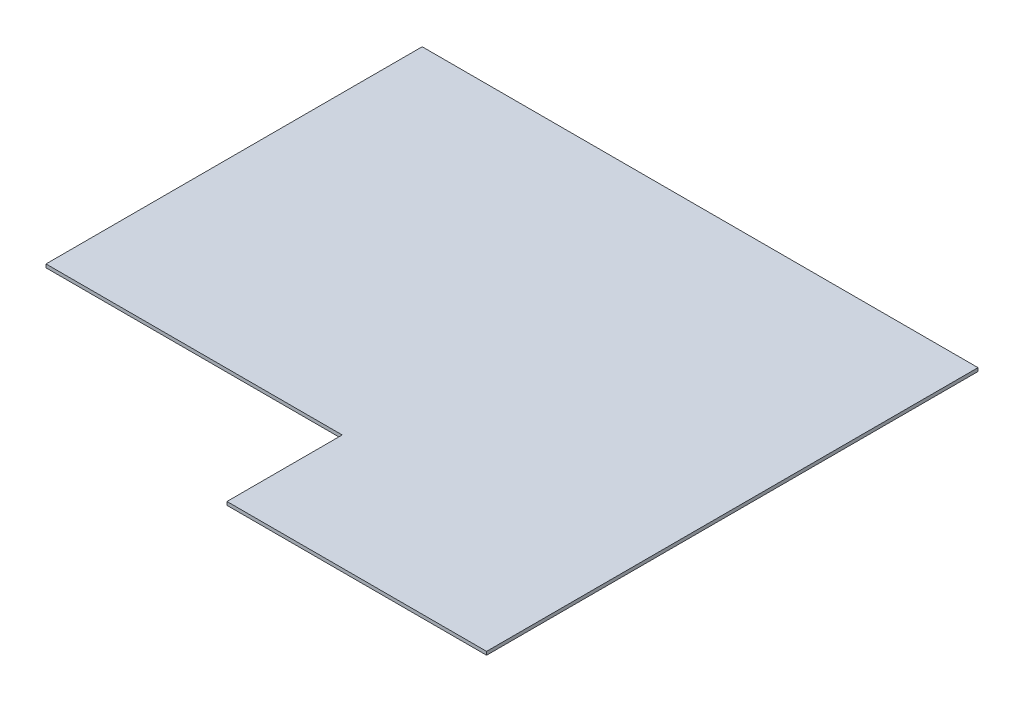
from build123d import *

# Parameters (mm, degrees)
EXTRUDE_1_DEPTH = 100


with BuildPart() as part:
    # Эскиз1 → Вытянуть1 (new body)
    with BuildSketch(Plane(origin=(0, 0, 0), x_dir=(1, 0, 0), z_dir=(0, 1, 0))):
        Polygon((0, 14500), (16400, 14500), (16400, 0), (8740, 0), (8740, 3400), (0, 3400), align=None)
    extrude(amount=EXTRUDE_1_DEPTH)


solid = part.part
